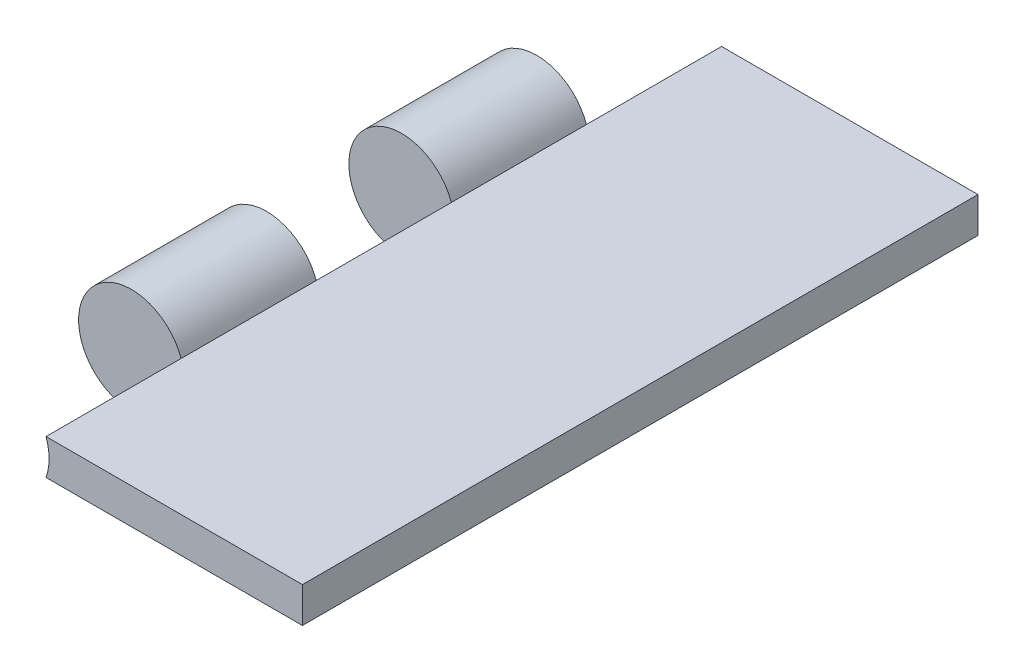
from build123d import *

# Parameters (mm, degrees)
BOSS_EXTRUDE1_DEPTH = 101.6
CUT_EXTRUDE1_DEPTH  = 20.32
CUT_EXTRUDE2_START  = 40.64
CUT_EXTRUDE2_DEPTH  = 20.32
CUT_EXTRUDE3_START  = 81.28
CUT_EXTRUDE3_DEPTH  = 20.32


with BuildPart() as part:
    # Sketch1 → Boss-Extrude1 (new body)
    with BuildSketch(Plane.XY):
        with BuildLine():
            Line((46.0375, 2.667), (7.476029511, 2.667))
            ThreePointArc((7.476029511, 2.667), (-7.9375, 0), (7.476029511, -2.667))
            Line((7.476029511, -2.667), (46.0375, -2.667))
            Line((46.0375, -2.667), (46.0375, 2.667))
        make_face()
    extrude(amount=BOSS_EXTRUDE1_DEPTH)

    # Sketch1_3 → Cut-Extrude1 (cut)
    with BuildSketch(Plane.XY):
        with BuildLine():
            ThreePointArc((7.476029511, 2.667), (-7.9375, 0), (7.476029511, -2.667))
            ThreePointArc((7.476029511, -2.667), (7.82128156, -1.35331482), (7.9375, 0))
            ThreePointArc((7.9375, 0), (7.82128156, 1.35331482), (7.476029511, 2.667))
        make_face()
    extrude(amount=CUT_EXTRUDE1_DEPTH, mode=Mode.SUBTRACT)

    # Sketch1_5 → Cut-Extrude2 (cut)
    with BuildSketch(Plane.XY.offset(CUT_EXTRUDE2_START)):
        with BuildLine():
            ThreePointArc((7.476029511, 2.667), (-7.9375, 0), (7.476029511, -2.667))
            ThreePointArc((7.476029511, -2.667), (7.82128156, -1.35331482), (7.9375, 0))
            ThreePointArc((7.9375, 0), (7.82128156, 1.35331482), (7.476029511, 2.667))
        make_face()
    extrude(amount=CUT_EXTRUDE2_DEPTH, mode=Mode.SUBTRACT)

    # Sketch1_6 → Cut-Extrude3 (cut)
    with BuildSketch(Plane.XY.offset(CUT_EXTRUDE3_START)):
        with BuildLine():
            ThreePointArc((7.476029511, 2.667), (-7.9375, 0), (7.476029511, -2.667))
            ThreePointArc((7.476029511, -2.667), (7.82128156, -1.35331482), (7.9375, 0))
            ThreePointArc((7.9375, 0), (7.82128156, 1.35331482), (7.476029511, 2.667))
        make_face()
    extrude(amount=CUT_EXTRUDE3_DEPTH, mode=Mode.SUBTRACT)


solid = part.part
